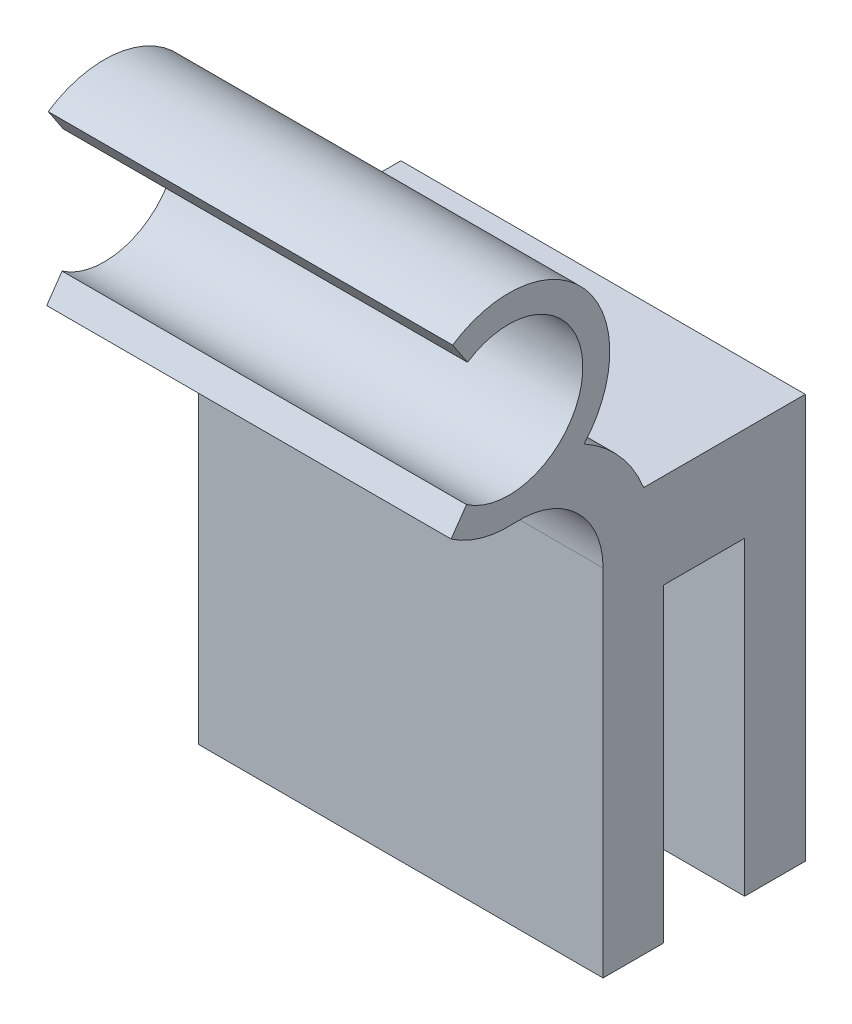
from build123d import *

# Parameters (mm, degrees)
SALIENTE_EXTRUIR1_DEPTH = 15


with BuildPart() as part:
    # Croquis1 → Saliente-Extruir1 (new body, symmetric)
    with BuildSketch(Plane(origin=(0, 0, 0), x_dir=(0, 0, -1), z_dir=(1, 0, 0))):
        with BuildLine():
            Line((-4.485879944, 10.519685039), (7.5, 10.519685039))
            Line((7.5, 10.519685039), (7.5, -19.480314961))
            Line((7.5, -19.480314961), (3, -19.480314961))
            Line((3, -19.480314961), (3, 3.519685039))
            Line((3, 3.519685039), (-3, 3.519685039))
            Line((-3, 3.519685039), (-3, -19.480314961))
            Line((-3, -19.480314961), (-7.5, -19.480314961))
            Line((-7.5, -19.480314961), (-7.5, 6.862248573))
            ThreePointArc((-7.5, 6.862248573), (-9.443341526, 11.362312215), (-14.051551981, 13.033104086))
            ThreePointArc((-14.051551981, 13.033104086), (-16.52030717, 13.29691833), (-18.767660033, 14.35226436))
            Line((-18.767660033, 14.35226436), (-17.629617358, 15.996909874))
            ThreePointArc((-17.629617358, 15.996909874), (-9.000210285, 20.471590491), (-17.550043283, 25.096500086))
            Line((-17.550043283, 25.096500086), (-18.659149931, 26.760796467))
            ThreePointArc((-18.659149931, 26.760796467), (-8.837821951, 25.437991632), (-8.902233659, 15.528191075))
            ThreePointArc((-8.902233659, 15.528191075), (-6.25888029, 13.407663941), (-4.485879944, 10.519685039))
        make_face()
    extrude(amount=SALIENTE_EXTRUIR1_DEPTH, both=True)


solid = part.part
